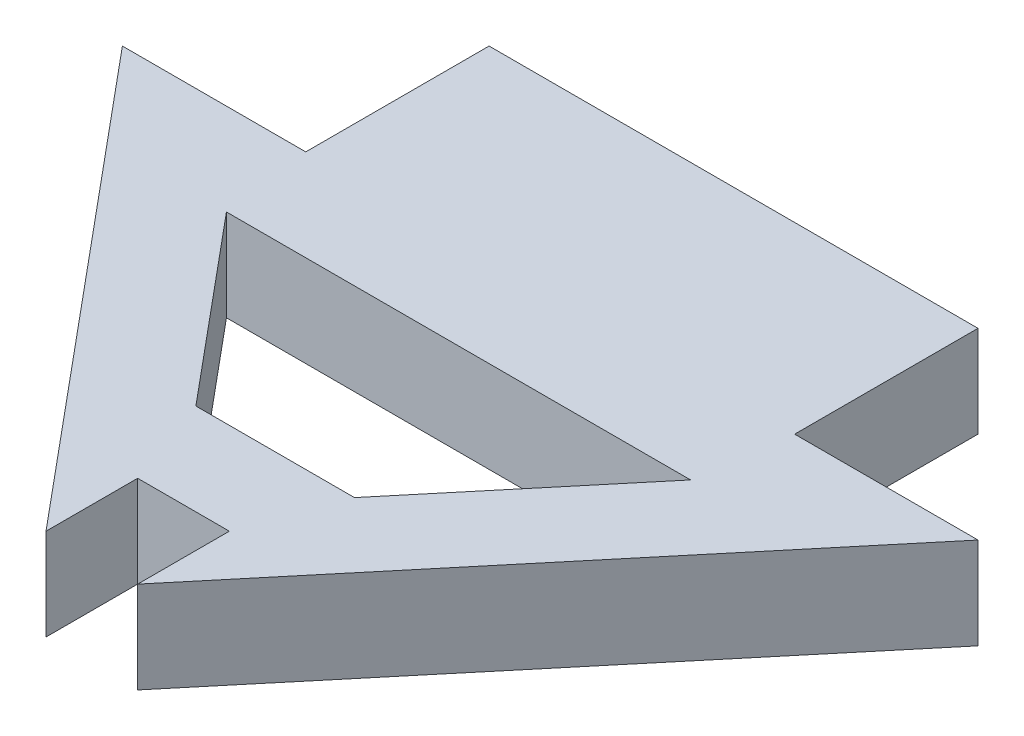
from build123d import *

# Parameters (mm, degrees)
BOSS_EXTRUDE1_DEPTH = 3


with BuildPart() as part:
    # Sketch1 → Boss-Extrude1 (new body)
    with BuildSketch(Plane(origin=(0, 0, 0), x_dir=(1, 0, 0), z_dir=(0, 1, 0))):
        Polygon((22.079481216, 3.028725772), (16.079481216, 3.028725772), (16.079481216, 9.028725772), (0.079481216, 9.028725772), (0.079481216, 3.028725772), (-5.920518784, 3.028725772), (6.579481216, -11.971274228), (6.579481216, -8.971274228), (9.579481216, -8.971274228), (9.579481216, -11.971274228), align=None)
        Polygon((15.674356378, 0.028725772), (0.484606054, 0.028725772), (5.484606054, -5.971274228), (10.674356378, -5.971274228), align=None, mode=Mode.SUBTRACT)
    extrude(amount=BOSS_EXTRUDE1_DEPTH)


solid = part.part
